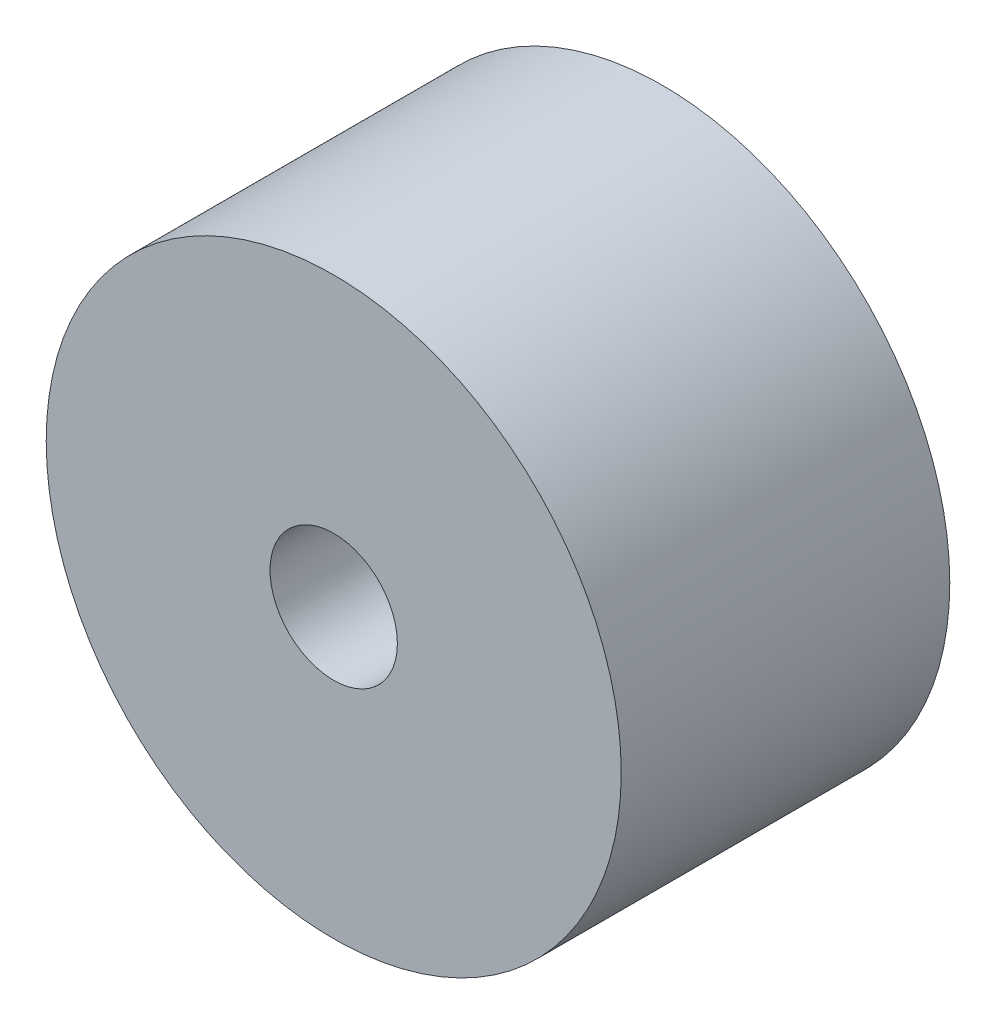
from build123d import *

# Parameters (mm, degrees)
SKETCH1_R           = 7
BOSS_EXTRUDE1_DEPTH = 8
SKETCH2_R           = 1.55
CUT_EXTRUDE1_DEPTH  = 3


with BuildPart() as part:
    # Sketch1 → Boss-Extrude1 (new body)
    with BuildSketch(Plane.XY):
        Circle(SKETCH1_R)
    extrude(amount=BOSS_EXTRUDE1_DEPTH)

    # Sketch2 → Cut-Extrude1 (cut)
    with BuildSketch(Plane.XY.offset(8)):
        Circle(SKETCH2_R)
    extrude(amount=-CUT_EXTRUDE1_DEPTH, mode=Mode.SUBTRACT)


solid = part.part
